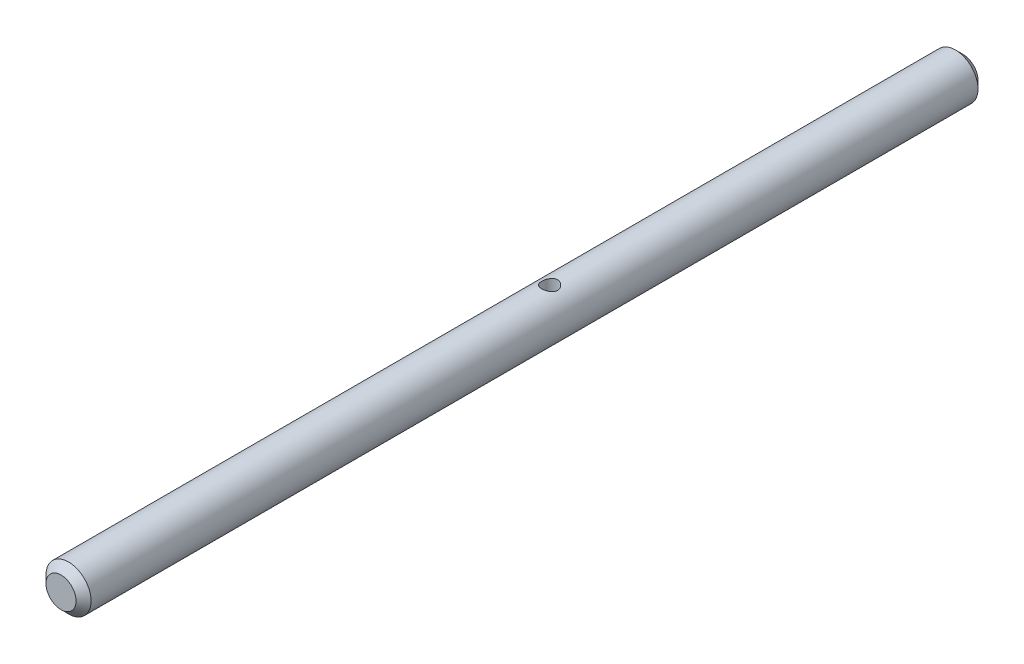
from build123d import *

# Parameters (mm, degrees)
SZKIC1_R                        = 3
DODANIE_WYCI_GNI_CIE1_DEPTH     = 65
DODANIE_WYCI_GNI_CIE2_START     = 65
SZKIC1_2_R                      = 3
DODANIE_WYCI_GNI_CIE2_DEPTH     = 120
SFAZOWANIE1_SIZE                = 1
SZKIC2_R                        = 1.05
WYTNIJ_WYCI_GNI_CIE1_DEPTH      = 4
WYTNIJ_WYCI_GNI_CIE1_DEPTH_BACK = 4


with BuildPart() as part:
    # Szkic1 → Dodanie-wyci_gni_cie1 (new body)
    with BuildSketch(Plane.XY):
        Circle(SZKIC1_R)
    extrude(amount=DODANIE_WYCI_GNI_CIE1_DEPTH)

    # Szkic1_2 → Dodanie-wyci_gni_cie2 (add)
    with BuildSketch(Plane.XY.offset(DODANIE_WYCI_GNI_CIE2_START)):
        Circle(SZKIC1_2_R)
    extrude(amount=-DODANIE_WYCI_GNI_CIE2_DEPTH)

    # Sfazowanie1
    sfazowanie1_edges = [part.edges().sort_by_distance(p)[0] for p in [
        (-3, 0, 65),
        (-3, 0, -55),
    ]]
    chamfer(sfazowanie1_edges, length=SFAZOWANIE1_SIZE)

    # Szkic2 → Wytnij-wyci_gni_cie1 (cut, two sides)
    with BuildSketch(Plane(origin=(0, 0, 0), x_dir=(1, 0, 0), z_dir=(0, 1, 0))) as wytnij_wyci_gni_cie1_sk:
        Circle(SZKIC2_R)
    extrude(amount=WYTNIJ_WYCI_GNI_CIE1_DEPTH, mode=Mode.SUBTRACT)
    extrude(wytnij_wyci_gni_cie1_sk.sketch, amount=-WYTNIJ_WYCI_GNI_CIE1_DEPTH_BACK, mode=Mode.SUBTRACT)


solid = part.part
